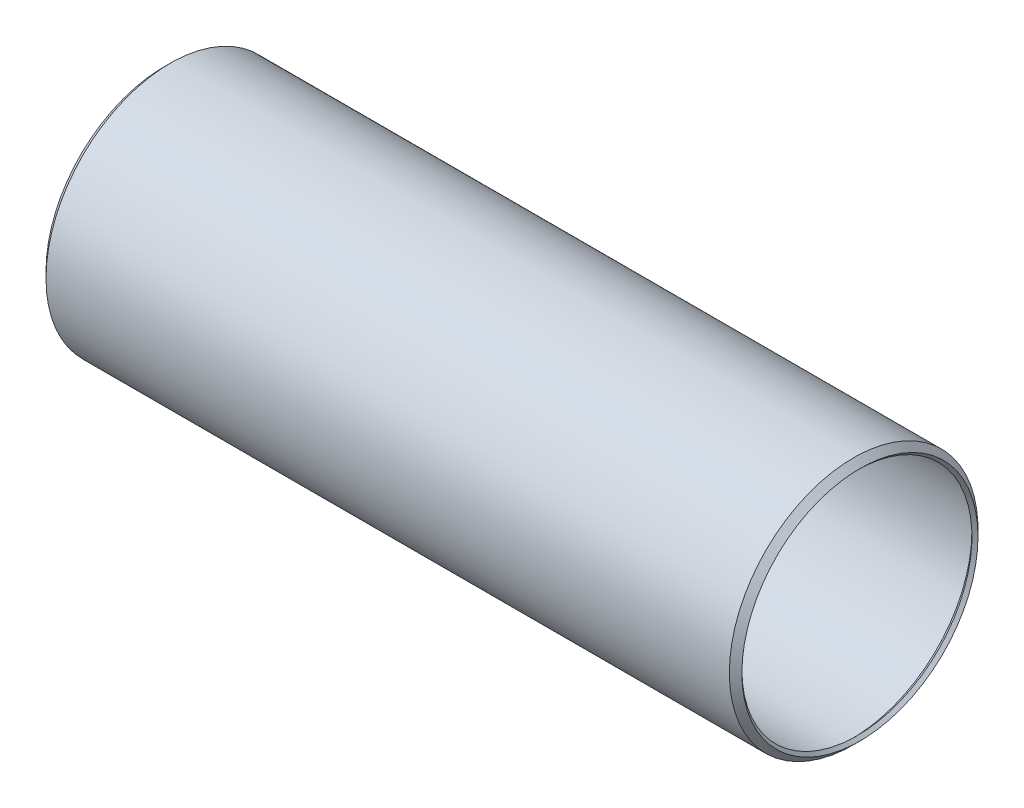
from build123d import *


with BuildPart() as part:
    # Sketch1 → Revolve1 (revolve)
    with BuildSketch(Plane.XY):
        Polygon((-139.178178441, 25.157578441), (-138.5316, 24.511), (-137.4648, 25.5778), (7.3914, 25.5778), (8.4582, 24.511), (9.104778441, 25.157578441), (7.770156881, 26.4922), (-137.843556881, 26.4922), align=None)
    revolve(axis=Axis((7.3914, 0, 0), (-1, 0, 0)))


solid = part.part
